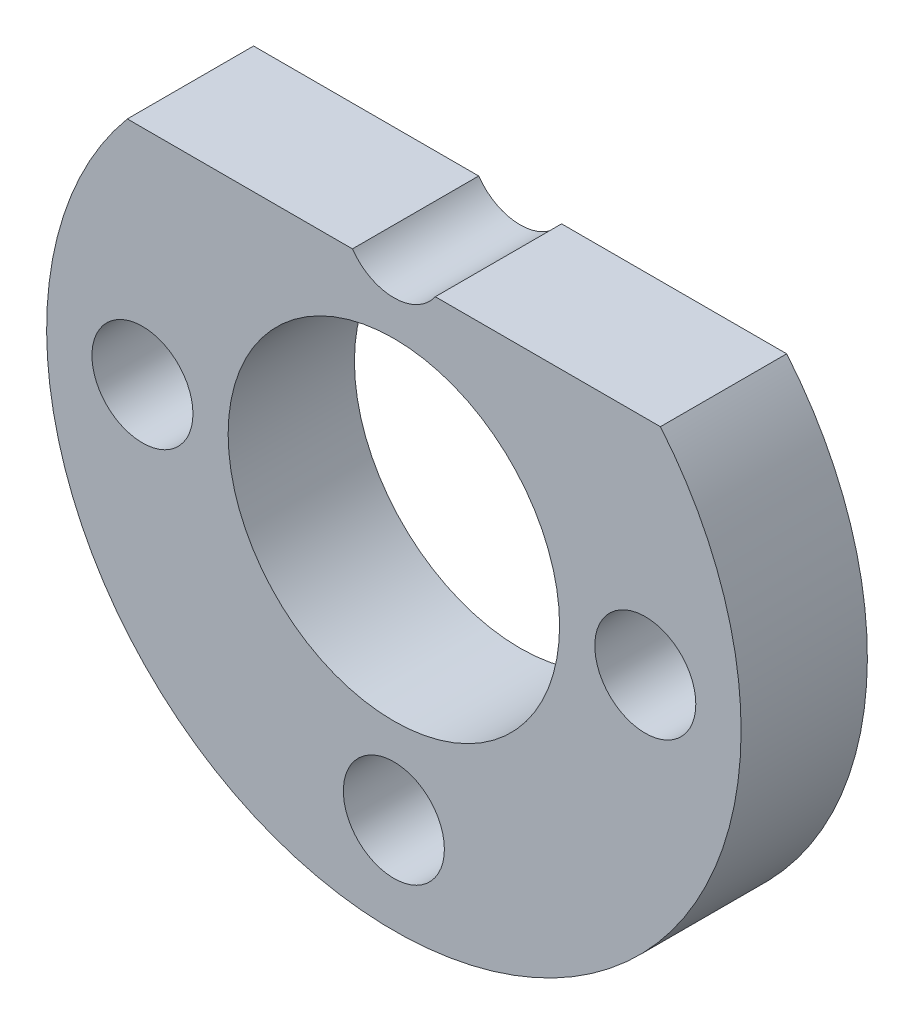
from build123d import *

# Parameters (mm, degrees)
RESSALTO_EXTRUS_O1_DEPTH = 4
ESBO_O2_R                = 5.25
CORTE_EXTRUS_O1_DEPTH    = 4
M3_CLEARANCE_HOLE1_D     = 3.2


with BuildPart() as part:
    # Esboço1 → Ressalto-extrusão1 (new body)
    with BuildSketch(Plane.XY):
        with BuildLine():
            Line((95.202808527, -295.7159332), (112.09037792, -295.7159332))
            ThreePointArc((112.09037792, -295.7159332), (103.646593224, -313.7659332), (95.202808527, -295.7159332))
        make_face()
    extrude(amount=RESSALTO_EXTRUS_O1_DEPTH)

    # Esboço2 → Corte-extrusão1 (cut)
    with BuildSketch(Plane.XY.offset(4)):
        with Locations((103.646593224, -302.7659332)):
            Circle(ESBO_O2_R)
    extrude(amount=-CORTE_EXTRUS_O1_DEPTH, mode=Mode.SUBTRACT)

    # M3 Clearance Hole1 (through all)
    with Locations(Plane.XY.offset(4)):
        with Locations((95.681870132, -302.765933199), (111.611316315, -302.765933199), (103.646593224, -310.730656291), (103.646593224, -294.801210108)):
            Hole(M3_CLEARANCE_HOLE1_D / 2)


solid = part.part
